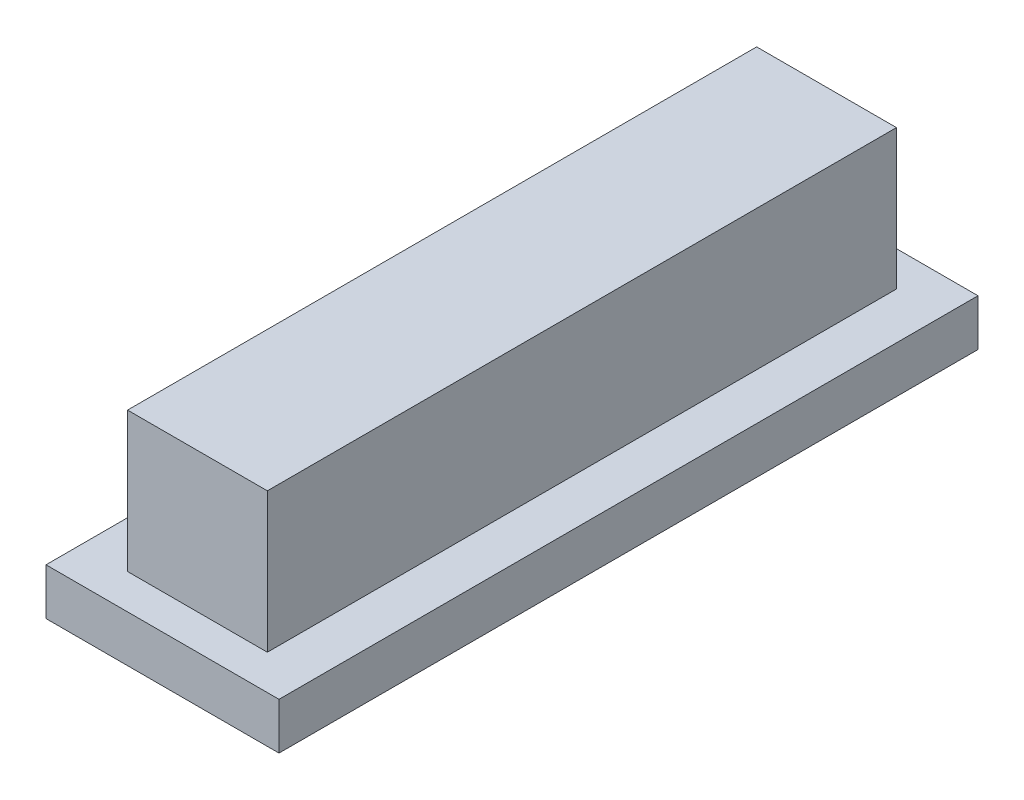
from build123d import *

# Parameters (mm, degrees)
SKETCH_1_W          = 6
SKETCH_1_H          = 27
SKETCH_1_W_2        = 3
SKETCH_1_H_2        = 22.2
EXTRUDE_1_DEPTH     = 4
SKETCH_2_W          = 6
SKETCH_2_H          = 27
EXTRUDE_2_DEPTH     = 2
SKETCH_3_W          = 10
SKETCH_3_H          = 30
EXTRUDE_3_DEPTH     = 2
SKETCH_4_W          = 5.9
SKETCH_4_H          = 25
CUT_EXTRUDE_3_DEPTH = 2


with BuildPart() as part:
    # 草图1 → 凸台-拉伸1 (new body)
    with BuildSketch(Plane(origin=(0, 0, 0), x_dir=(1, 0, 0), z_dir=(0, 1, 0))):
        Rectangle(SKETCH_1_W, SKETCH_1_H)
        Rectangle(SKETCH_1_W_2, SKETCH_1_H_2, mode=Mode.SUBTRACT)
    extrude(amount=EXTRUDE_1_DEPTH)

    # 草图2 → 凸台-拉伸2 (add)
    with BuildSketch(Plane(origin=(0, 4, 0), x_dir=(1, 0, 0), z_dir=(0, 1, 0))):
        Rectangle(SKETCH_2_W, SKETCH_2_H)
    extrude(amount=EXTRUDE_2_DEPTH)

    # 草图3 → 凸台-拉伸3 (add)
    with BuildSketch(Plane.XZ):
        Rectangle(SKETCH_3_W, SKETCH_3_H)
    extrude(amount=EXTRUDE_3_DEPTH)

    # 草图4 → 切除-拉伸3 (cut)
    with BuildSketch(Plane.XZ.offset(2)):
        Rectangle(SKETCH_4_W, SKETCH_4_H)
    extrude(amount=-CUT_EXTRUDE_3_DEPTH, mode=Mode.SUBTRACT)


solid = part.part
